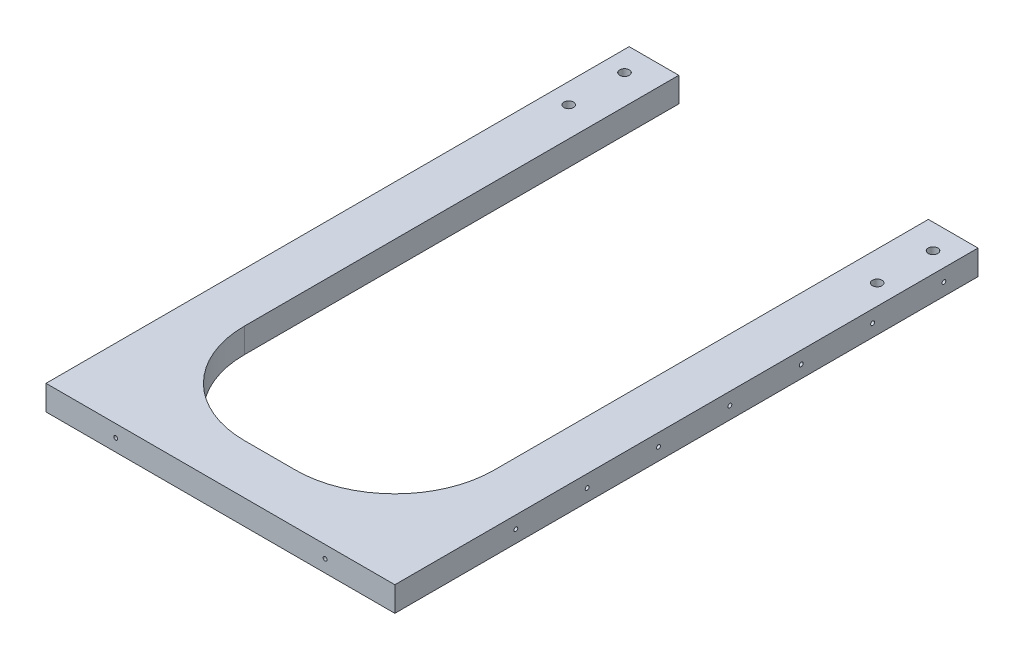
from build123d import *

# Parameters (mm, degrees)
SKETCH1_W                                 = 178.5366
SKETCH1_H                                 = 12.7
BOSS_EXTRUDE1_DEPTH                       = 342.9
CUT_EXTRUDE1_REACH                        = 14.7
SKETCH2_W                                 = 127.7366
SKETCH2_H                                 = 292.1
FILLET1_R                                 = 50.8
F_15_64_0_23438_DIAMETER_HOLE2_D          = 5.953252
F_15_64_0_23438_DIAMETER_HOLE2_DEPTH      = 12.7
F_15_64_0_23438_DIAMETER_HOLE2_TIP        = 1.788537341
F_5_64_0_07813_DIAMETER_HOLE1_D           = 1.984502
F_5_64_0_07813_DIAMETER_HOLE1_DEPTH       = 38.1
F_5_64_0_07813_DIAMETER_HOLE1_CSINK_D     = 10.16
F_5_64_0_07813_DIAMETER_HOLE1_CSINK_ANGLE = 82
F_5_64_0_07813_DIAMETER_HOLE1_TIP         = 0.59620455
F_5_64_0_07813_DIAMETER_HOLE2_AT_2_COUNT  = 2
F_5_64_0_07813_DIAMETER_HOLE2_AT_2_PITCH  = 36.5125
F_5_64_0_07813_DIAMETER_HOLE2_AT_3_COUNT  = 2
F_5_64_0_07813_DIAMETER_HOLE2_AT_3_PITCH  = 73.025
F_5_64_0_07813_DIAMETER_HOLE2_AT_4_COUNT  = 2
F_5_64_0_07813_DIAMETER_HOLE2_AT_4_PITCH  = 109.5375
F_5_64_0_07813_DIAMETER_HOLE2_AT_5_COUNT  = 2
F_5_64_0_07813_DIAMETER_HOLE2_AT_5_PITCH  = 146.05
F_5_64_0_07813_DIAMETER_HOLE2_AT_6_COUNT  = 2
F_5_64_0_07813_DIAMETER_HOLE2_AT_6_PITCH  = 182.5625
F_5_64_0_07813_DIAMETER_HOLE2_AT_7_COUNT  = 2
F_5_64_0_07813_DIAMETER_HOLE2_AT_7_PITCH  = 219.075
CUT_EXTRUDE2_REACH                        = 14.7
SKETCH11_W                                = 178.5366
SKETCH11_H                                = 44.45
CUT_EXTRUDE3_START                        = -12.7
SKETCH12_W                                = 127.7366
SKETCH12_H                                = 31.75
CUT_EXTRUDE3_DEPTH                        = 12.7
F_8_CLEARANCE_HOLE1_D                     = 4.9149


with BuildPart() as part:
    # Sketch1 → Boss-Extrude1 (new body)
    with BuildSketch(Plane.XY):
        with Locations((-182.40375, -186.69)):
            Rectangle(SKETCH1_W, SKETCH1_H)
    extrude(amount=BOSS_EXTRUDE1_DEPTH)

    # Sketch2 → Cut-Extrude1 (cut, up to next)
    with BuildSketch(Plane.XZ.offset(193.04), mode=Mode.PRIVATE) as cut_extrude1_sk1:
        with Locations((-182.40375, 171.45)):
            Rectangle(SKETCH2_W, SKETCH2_H)
    cut_extrude1_tool1 = extrude(cut_extrude1_sk1.sketch, amount=-CUT_EXTRUDE1_REACH, mode=Mode.PRIVATE) & part.part
    add(cut_extrude1_tool1.solids().sort_by_distance((-182.40375, -193.04, 171.45))[0], mode=Mode.SUBTRACT)

    # Fillet1
    fillet1_edges = [part.edges().sort_by_distance(p)[0] for p in [
        (-118.53545, -186.69, 317.5),
        (-118.53545, -186.69, 25.4),
        (-246.27205, -186.69, 25.4),
        (-246.27205, -186.69, 317.5),
    ]]
    fillet(fillet1_edges, radius=FILLET1_R)

    # 15/64 (0.23438) Diameter Hole2
    with Locations(Plane(origin=(-182.40375, 1936.853954382, -6.35), x_dir=(1, 0, 0), z_dir=(0, 0, -1))):
        with Locations((-262.8265, 2051.088542934), (-262.8265, 2014.068680083), (-262.8265, 1977.048817232), (-98.7933, 2115.959791125), (-98.7933, 2151.166454382), (-44.63415, 2123.543954382), (0, 2123.543954382), (44.63415, 2123.543954382)):
            Hole(F_15_64_0_23438_DIAMETER_HOLE2_D / 2, depth=F_15_64_0_23438_DIAMETER_HOLE2_DEPTH)
            with Locations((0, 0, -(F_15_64_0_23438_DIAMETER_HOLE2_DEPTH + F_15_64_0_23438_DIAMETER_HOLE2_TIP / 2))):  # 118° drill point
                Cone(0, F_15_64_0_23438_DIAMETER_HOLE2_D / 2, F_15_64_0_23438_DIAMETER_HOLE2_TIP, mode=Mode.SUBTRACT)

    # 5/64 (0.07813) Diameter Hole1
    with Locations(Plane(origin=(-182.40375, 1936.853954382, 361.95), x_dir=(-1, 0, 0), z_dir=(0, 0, 1))):
        with Locations((-262.508471454, 2038.114708605), (262.8265, 2038.74858865), (262.8265, 1989.388771516), (262.8265, 1964.708862949), (262.8265, 2014.068680083), (262.8265, 2063.428497217), (98.7933, 2131.851871048), (98.7933, 2093.487287715), (98.7933, 2055.122704382), (98.7933, 2016.758121048), (98.7933, 1978.393537715), (53.56098, 2123.543954382), (-53.56098, 2123.543954382), (-98.330098001, 1978.155684545), (-98.422680867, 2016.520156166), (-98.515263732, 2054.884627786), (-98.607846597, 2093.249099407), (-98.700429462, 2131.613571028), (-262.568029943, 2062.794545307), (-262.448912964, 2013.434871902), (-262.329795984, 1964.075198497), (-262.389354474, 1988.755035199)):
            CounterSinkHole(F_5_64_0_07813_DIAMETER_HOLE1_D / 2, F_5_64_0_07813_DIAMETER_HOLE1_CSINK_D / 2, depth=F_5_64_0_07813_DIAMETER_HOLE1_DEPTH, counter_sink_angle=F_5_64_0_07813_DIAMETER_HOLE1_CSINK_ANGLE)
            with Locations((0, 0, -(F_5_64_0_07813_DIAMETER_HOLE1_DEPTH + F_5_64_0_07813_DIAMETER_HOLE1_TIP / 2))):  # 118° drill point
                Cone(0, F_5_64_0_07813_DIAMETER_HOLE1_D / 2, F_5_64_0_07813_DIAMETER_HOLE1_TIP, mode=Mode.SUBTRACT)

    # Sketch10 → 5/64 (0.07813) Diameter Hole2 (revolve, cut)
    with BuildSketch(Plane(origin=(-271.67205, -186.69, 280.9875), x_dir=(0, 0, 1), z_dir=(0, 1, 0))):
        Polygon((0, 0), (0, 19.64620455), (0.992251, 19.05), (0.992251, 0), align=None)
    f_5_64_0_07813_diameter_hole2 = revolve(axis=Axis((-278.02205, -186.69, 280.9875), (1, 0, 0)), mode=Mode.SUBTRACT)

    # 5/64 (0.07813) Diameter Hole2 at 2: 5/64 (0.07813) Diameter Hole2 ×2
    with Locations(*[(0, 0, -i * F_5_64_0_07813_DIAMETER_HOLE2_AT_2_PITCH) for i in range(1, F_5_64_0_07813_DIAMETER_HOLE2_AT_2_COUNT)]):
        add(f_5_64_0_07813_diameter_hole2, mode=Mode.SUBTRACT)

    # 5/64 (0.07813) Diameter Hole2 at 3: 5/64 (0.07813) Diameter Hole2 ×2
    with Locations(*[(0, 0, -i * F_5_64_0_07813_DIAMETER_HOLE2_AT_3_PITCH) for i in range(1, F_5_64_0_07813_DIAMETER_HOLE2_AT_3_COUNT)]):
        add(f_5_64_0_07813_diameter_hole2, mode=Mode.SUBTRACT)

    # 5/64 (0.07813) Diameter Hole2 at 4: 5/64 (0.07813) Diameter Hole2 ×2
    with Locations(*[(0, 0, -i * F_5_64_0_07813_DIAMETER_HOLE2_AT_4_PITCH) for i in range(1, F_5_64_0_07813_DIAMETER_HOLE2_AT_4_COUNT)]):
        add(f_5_64_0_07813_diameter_hole2, mode=Mode.SUBTRACT)

    # 5/64 (0.07813) Diameter Hole2 at 5: 5/64 (0.07813) Diameter Hole2 ×2
    with Locations(*[(0, 0, -i * F_5_64_0_07813_DIAMETER_HOLE2_AT_5_PITCH) for i in range(1, F_5_64_0_07813_DIAMETER_HOLE2_AT_5_COUNT)]):
        add(f_5_64_0_07813_diameter_hole2, mode=Mode.SUBTRACT)

    # 5/64 (0.07813) Diameter Hole2 at 6: 5/64 (0.07813) Diameter Hole2 ×2
    with Locations(*[(0, 0, -i * F_5_64_0_07813_DIAMETER_HOLE2_AT_6_PITCH) for i in range(1, F_5_64_0_07813_DIAMETER_HOLE2_AT_6_COUNT)]):
        add(f_5_64_0_07813_diameter_hole2, mode=Mode.SUBTRACT)

    # 5/64 (0.07813) Diameter Hole2 at 7: 5/64 (0.07813) Diameter Hole2 ×2
    with Locations(*[(0, 0, -i * F_5_64_0_07813_DIAMETER_HOLE2_AT_7_PITCH) for i in range(1, F_5_64_0_07813_DIAMETER_HOLE2_AT_7_COUNT)]):
        add(f_5_64_0_07813_diameter_hole2, mode=Mode.SUBTRACT)

    # Mirror1: 5/64 (0.07813) Diameter Hole2 across plane
    add(f_5_64_0_07813_diameter_hole2.mirror(Plane.ZY.offset(182.40375)), mode=Mode.SUBTRACT)

    # Mirror1 copy 1 sketch → Mirror1 copy 1 (revolve, cut)
    with BuildSketch(Plane(origin=(-93.13545, -186.69, 244.475), x_dir=(0, 0, 1), z_dir=(0, 1, 0))):
        Polygon((0, 0), (0, -19.64620455), (0.992251, -19.05), (0.992251, 0), align=None)
    revolve(axis=Axis((-86.78545, -186.69, 244.475), (1, 0, 0)), mode=Mode.SUBTRACT)

    # Mirror1 copy 2 sketch → Mirror1 copy 2 (revolve, cut)
    with BuildSketch(Plane(origin=(-93.13545, -186.69, 207.9625), x_dir=(0, 0, 1), z_dir=(0, 1, 0))):
        Polygon((0, 0), (0, -19.64620455), (0.992251, -19.05), (0.992251, 0), align=None)
    revolve(axis=Axis((-86.78545, -186.69, 207.9625), (1, 0, 0)), mode=Mode.SUBTRACT)

    # Mirror1 copy 3 sketch → Mirror1 copy 3 (revolve, cut)
    with BuildSketch(Plane(origin=(-93.13545, -186.69, 171.45), x_dir=(0, 0, 1), z_dir=(0, 1, 0))):
        Polygon((0, 0), (0, -19.64620455), (0.992251, -19.05), (0.992251, 0), align=None)
    revolve(axis=Axis((-86.78545, -186.69, 171.45), (1, 0, 0)), mode=Mode.SUBTRACT)

    # Mirror1 copy 4 sketch → Mirror1 copy 4 (revolve, cut)
    with BuildSketch(Plane(origin=(-93.13545, -186.69, 134.9375), x_dir=(0, 0, 1), z_dir=(0, 1, 0))):
        Polygon((0, 0), (0, -19.64620455), (0.992251, -19.05), (0.992251, 0), align=None)
    revolve(axis=Axis((-86.78545, -186.69, 134.9375), (1, 0, 0)), mode=Mode.SUBTRACT)

    # Mirror1 copy 5 sketch → Mirror1 copy 5 (revolve, cut)
    with BuildSketch(Plane(origin=(-93.13545, -186.69, 98.425), x_dir=(0, 0, 1), z_dir=(0, 1, 0))):
        Polygon((0, 0), (0, -19.64620455), (0.992251, -19.05), (0.992251, 0), align=None)
    revolve(axis=Axis((-86.78545, -186.69, 98.425), (1, 0, 0)), mode=Mode.SUBTRACT)

    # Mirror1 copy 6 sketch → Mirror1 copy 6 (revolve, cut)
    with BuildSketch(Plane(origin=(-93.13545, -186.69, 61.9125), x_dir=(0, 0, 1), z_dir=(0, 1, 0))):
        Polygon((0, 0), (0, -19.64620455), (0.992251, -19.05), (0.992251, 0), align=None)
    revolve(axis=Axis((-86.78545, -186.69, 61.9125), (1, 0, 0)), mode=Mode.SUBTRACT)

    # Sketch11 → Cut-Extrude2 (cut, up to next)
    with BuildSketch(Plane.XZ.offset(193.04), mode=Mode.PRIVATE) as cut_extrude2_sk1:
        with Locations((-182.40375, 22.225)):
            Rectangle(SKETCH11_W, SKETCH11_H)
    cut_extrude2_tool1 = extrude(cut_extrude2_sk1.sketch, amount=-CUT_EXTRUDE2_REACH, mode=Mode.PRIVATE) & part.part
    add(cut_extrude2_tool1.solids().sort_by_distance((-182.40375, -193.04, 22.225))[0], mode=Mode.SUBTRACT)

    # Sketch12 → Cut-Extrude3 (cut)
    with BuildSketch(Plane.XZ.offset(193.04).offset(CUT_EXTRUDE3_START)):
        with Locations((-182.40375, 60.325)):
            Rectangle(SKETCH12_W, SKETCH12_H)
    extrude(amount=CUT_EXTRUDE3_DEPTH, mode=Mode.SUBTRACT)

    # #8 Clearance Hole1 (through all)
    with Locations(Plane(origin=(0, -193.04, 0), x_dir=(-1, 0, 0), z_dir=(0, -1, 0))):
        with Locations((261.3533, -85.725), (261.3533, -57.15), (103.4542, -57.15), (103.4542, -85.725)):
            Hole(F_8_CLEARANCE_HOLE1_D / 2)


solid = part.part
